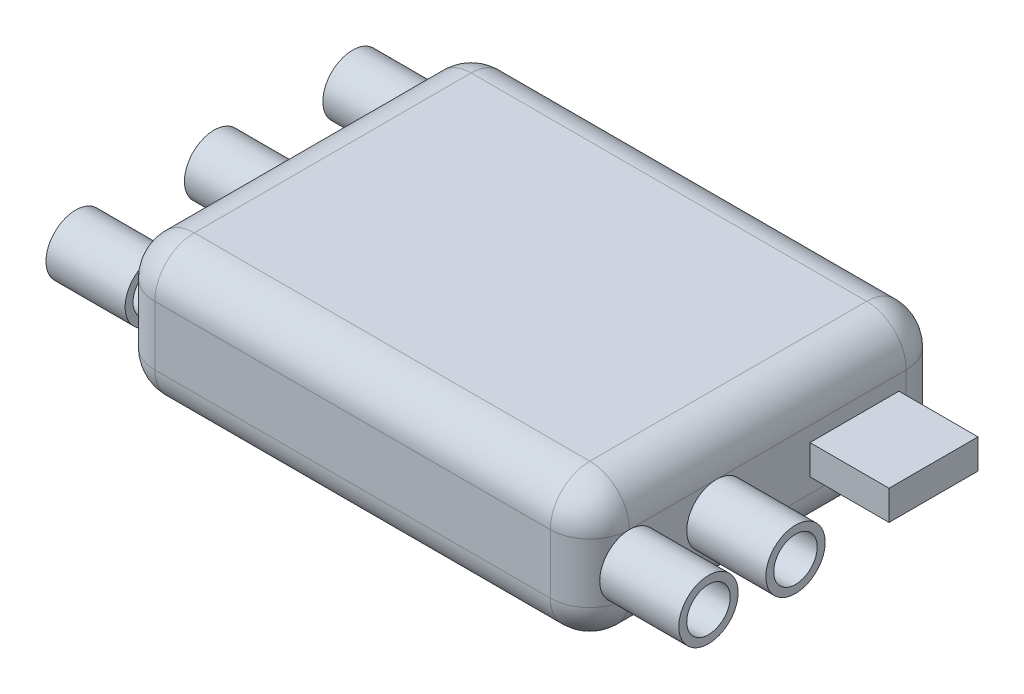
from build123d import *

# Parameters (mm, degrees)
BOSS_EXTRUDE1_DEPTH = 7
FILLET1_R           = 2
SKETCH2_R           = 1.5
SKETCH2_R_2         = 1.1
BOSS_EXTRUDE2_DEPTH = 4
SKETCH3_R           = 1.5
SKETCH3_R_2         = 1.1
SKETCH3_W           = 4.5
SKETCH3_H           = 1.5
BOSS_EXTRUDE3_DEPTH = 4


with BuildPart() as part:
    # Sketch1 → Boss-Extrude1 (new body)
    with BuildSketch(Plane(origin=(0, 0, 0), x_dir=(1, 0, 0), z_dir=(0, 1, 0))):
        with BuildLine():
            Line((-10, 9), (10, 9))
            ThreePointArc((10, 9), (11.414213562, 8.414213562), (12, 7))
            Line((12, 7), (12, -7))
            ThreePointArc((12, -7), (11.414213562, -8.414213562), (10, -9))
            Line((10, -9), (-10, -9))
            ThreePointArc((-10, -9), (-11.414213562, -8.414213562), (-12, -7))
            Line((-12, -7), (-12, 7))
            ThreePointArc((-12, 7), (-11.414213562, 8.414213562), (-10, 9))
        make_face()
    extrude(amount=BOSS_EXTRUDE1_DEPTH)

    # Fillet1
    fillet1_edges = [part.edges().sort_by_distance(p)[0] for p in [
        (-12, 0, 0),
        (-11.414213562, 0, -8.414213562),
        (0, 0, -9),
        (11.414213562, 0, -8.414213562),
        (-11.414213562, 7, -8.414213562),
        (-12, 7, 0),
        (-11.414213562, 7, 8.414213562),
        (0, 7, 9),
        (11.414213562, 7, 8.414213562),
        (12, 7, 0),
        (11.414213562, 7, -8.414213562),
        (12, 0, 0),
        (0, 7, -9),
        (11.414213562, 0, 8.414213562),
        (0, 0, 9),
        (-11.414213562, 0, 8.414213562),
    ]]
    fillet(fillet1_edges, radius=FILLET1_R)

    # Sketch2 → Boss-Extrude2 (add)
    with BuildSketch(Plane.ZY.offset(12)):
        with Locations((-7, 3.5)):
            Circle(SKETCH2_R)
        with Locations((-7, 3.5)):
            Circle(SKETCH2_R_2, mode=Mode.SUBTRACT)
        with Locations((0, 3.5)):
            Circle(SKETCH2_R)
        with Locations((0, 3.5)):
            Circle(SKETCH2_R_2, mode=Mode.SUBTRACT)
        with Locations((7, 3.5)):
            Circle(SKETCH2_R)
        with Locations((7, 3.5)):
            Circle(SKETCH2_R_2, mode=Mode.SUBTRACT)
    extrude(amount=BOSS_EXTRUDE2_DEPTH)

    # Sketch3 → Boss-Extrude3 (add)
    with BuildSketch(Plane(origin=(12, 0, 0), x_dir=(0, 0, -1), z_dir=(1, 0, 0))):
        with Locations((-7, 3.5)):
            Circle(SKETCH3_R)
        with Locations((-7, 3.5)):
            Circle(SKETCH3_R_2, mode=Mode.SUBTRACT)
        with Locations((-2.6, 3.5)):
            Circle(SKETCH3_R)
        with Locations((-2.6, 3.5)):
            Circle(SKETCH3_R_2, mode=Mode.SUBTRACT)
        with Locations((4.379211167, 3.5)):
            Rectangle(SKETCH3_W, SKETCH3_H)
    extrude(amount=BOSS_EXTRUDE3_DEPTH)


solid = part.part
